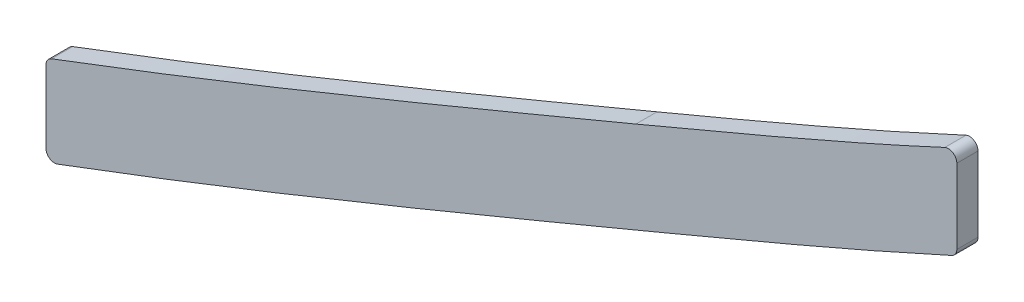
from build123d import *

# Parameters (mm, degrees)
BOSS_EXTRUDE1_DEPTH = 1.5875
FILLET1_R           = 1.27


with BuildPart() as part:
    # Sketch1 → Boss-Extrude1 (new body, symmetric)
    with BuildSketch(Plane.XY):
        with BuildLine():
            add(Edge.make_bspline(
                [(103.1875, 116.775644737), (134.083206396, 128.359547048), (165.188742148, 141.378538978), (191.60780158, 152.412778165)],
                knots=[0.120408431, 0.120408431, 0.120408431, 0.120408431, 1, 1, 1, 1], degree=3))
            Line((103.1875, 116.775644737), (103.1875, 103.221766291))
            add(Edge.make_bspline(
                [(103.1875, 103.221766291), (104.836346711, 103.832888895), (110.910789744, 106.099289805), (121.438654787, 110.116470414), (134.654525061, 115.297088101), (147.709166263, 120.526352792), (160.514652982, 125.743699314), (170.90961349, 130.032834424), (179.016898276, 133.399089085), (184.983371131, 135.884243485), (189.84810323, 137.914627663), (193.677721798, 139.514035727), (195.557921278, 140.299392887), (196.502354723, 140.69384692)],
                knots=[0.078438404, 0.078438404, 0.078438404, 0.078438404, 0.125, 0.25, 0.375, 0.5, 0.625, 0.75, 0.8125, 0.875, 0.9375, 0.96875, 1, 1, 1, 1], degree=3))
            add(Edge.make_bspline(
                [(196.502354723, 140.69384692), (200.472258679, 142.351925244), (208.383523136, 145.67023209), (220.364202496, 150.772038823), (230.422608344, 155.16713119), (236.88583627, 158.07892828), (239.315563949, 159.190103703), (239.7125, 159.372089547)],
                knots=[14.817810364, 14.817810364, 14.817810364, 14.817810364, 16.034279138, 17.250747911, 18.467216684, 19.075451071, 19.194157176, 19.194157176, 19.194157176, 19.194157176], degree=3))
            Line((239.7125, 159.372089547), (239.7125, 173.372303785))
            Line((239.7125, 173.372303785), (239.230812588, 173.146496258))
            add(Edge.make_bspline(
                [(191.60780158, 152.412778165), (201.07340942, 156.366203579), (210.566735216, 160.366210114), (220.096436884, 164.442364028), (229.661309686, 168.660462928), (239.230812588, 173.146496258)],
                knots=[14.817810364, 14.817810364, 14.817810364, 14.817810364, 14.817810364, 14.817810364, 19.683685458, 19.683685458, 19.683685458, 19.683685458, 19.683685458, 19.683685458], degree=5))
        make_face()
    extrude(amount=BOSS_EXTRUDE1_DEPTH, both=True)

    # Fillet1
    fillet1_edges = [part.edges().sort_by_distance(p)[0] for p in [
        (239.7125, 159.372089547, -0.79375),
        (239.7125, 173.372303785, 0),
        (103.1875, 103.221766291, -0.79375),
        (103.1875, 116.775644737, 0.79375),
    ]]
    fillet(fillet1_edges, radius=FILLET1_R)


solid = part.part
